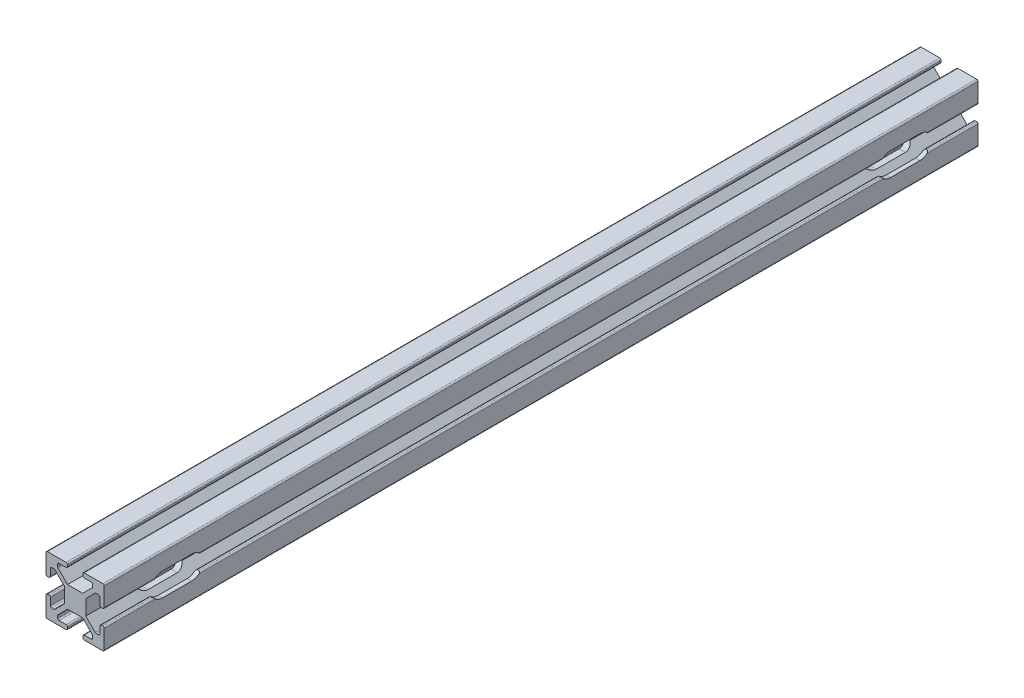
from build123d import *

# Parameters (mm, degrees)
BOSS_EXTRUDE1_DEPTH     = 300
FILLET1_R               = 0.5
CUT_EXTRUDE1_DEPTH      = 11
CUT_EXTRUDE1_DEPTH_BACK = 11


with BuildPart() as part:
    # Sketch1 → Boss-Extrude1 (new body)
    with BuildSketch(Plane.XY):
        Polygon((-10, 2.63), (-10, 10), (-2.63, 10), (-2.63, 8.5), (-5.995, 8.5), (-5.995, 7.055660172), (-2.594339828, 3.655), (2.594339828, 3.655), (5.995, 7.055660172), (5.995, 8.5), (2.63, 8.5), (2.63, 10), (10, 10), (10, 2.63), (8.5, 2.63), (8.5, 5.995), (7.055660172, 5.995), (3.655, 2.594339828), (3.655, -2.594339828), (7.055660172, -5.995), (8.5, -5.995), (8.5, -2.63), (10, -2.63), (10, -10), (2.63, -10), (2.63, -8.5), (5.995, -8.5), (5.995, -7.055660172), (2.594339828, -3.655), (-2.594339828, -3.655), (-5.995, -7.055660172), (-5.995, -8.5), (-2.63, -8.5), (-2.63, -10), (-10, -10), (-10, -2.63), (-8.5, -2.63), (-8.5, -5.995), (-7.055660172, -5.995), (-3.655, -2.594339828), (-3.655, 2.594339828), (-7.055660172, 5.995), (-8.5, 5.995), (-8.5, 2.63), align=None)
    extrude(amount=-BOSS_EXTRUDE1_DEPTH)

    # Fillet1
    fillet1_edges = [part.edges().sort_by_distance(p)[0] for p in [
        (-10, 2.63, -150),
        (-10, 10, -150),
        (-2.63, 10, -150),
        (-2.63, 8.5, -150),
        (-5.995, 8.5, -150),
        (-5.995, 7.055660172, -150),
        (5.995, 7.055660172, -150),
        (5.995, 8.5, -150),
        (2.63, 8.5, -150),
        (2.63, 10, -150),
        (10, 10, -150),
        (10, 2.63, -150),
        (8.5, 2.63, -150),
        (8.5, 5.995, -150),
        (7.055660172, 5.995, -150),
        (7.055660172, -5.995, -150),
        (8.5, -5.995, -150),
        (8.5, -2.63, -150),
        (10, -2.63, -150),
        (10, -10, -150),
        (2.63, -10, -150),
        (2.63, -8.5, -150),
        (5.995, -8.5, -150),
        (5.995, -7.055660172, -150),
        (-5.995, -7.055660172, -150),
        (-5.995, -8.5, -150),
        (-2.63, -8.5, -150),
        (-2.63, -10, -150),
        (-10, -10, -150),
        (-10, -2.63, -150),
        (-8.5, -2.63, -150),
        (-8.5, -5.995, -150),
        (-7.055660172, -5.995, -150),
        (-7.055660172, 5.995, -150),
        (-8.5, 5.995, -150),
        (-8.5, 2.63, -150),
    ]]
    fillet(fillet1_edges, radius=FILLET1_R)

    # Sketch2 → Cut-Extrude1 (cut, two sides)
    with BuildSketch(Plane(origin=(0, 0, 0), x_dir=(0, 0, -1), z_dir=(1, 0, 0))) as cut_extrude1_sk:
        with BuildLine():
            Line((20, 4), (30, 4))
            ThreePointArc((30, 4), (34, 0), (30, -4))
            Line((30, -4), (20, -4))
            ThreePointArc((20, -4), (16, 0), (20, 4))
        make_face()
        with BuildLine():
            Line((280, 4), (270, 4))
            ThreePointArc((270, 4), (266, 0), (270, -4))
            Line((270, -4), (280, -4))
            ThreePointArc((280, -4), (284, 0), (280, 4))
        make_face()
    extrude(amount=CUT_EXTRUDE1_DEPTH, mode=Mode.SUBTRACT)
    extrude(cut_extrude1_sk.sketch, amount=-CUT_EXTRUDE1_DEPTH_BACK, mode=Mode.SUBTRACT)


solid = part.part
